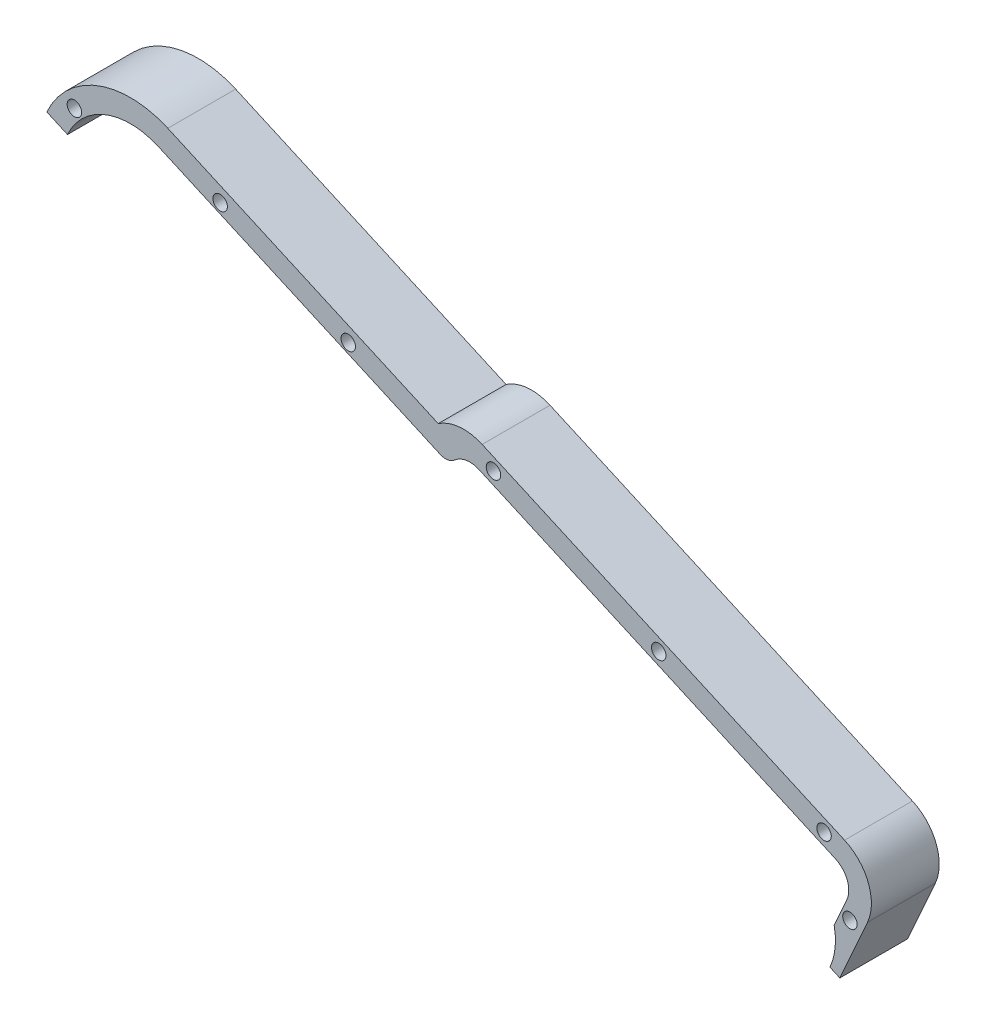
from build123d import *

# Parameters (mm, degrees)
SKETCH1_R           = 14.25
SKETCH1_R_2         = 1.7
SKETCH1_R_3         = 1.6
BOSS_EXTRUDE1_DEPTH = 15
SKETCH5_R           = 1.25
SKETCH5_R_2         = 1.6
CUT_EXTRUDE4_DEPTH  = 16
CUT_EXTRUDE5_DEPTH  = 16
FILLET1_R           = 5
FILLET2_R           = 5
CUT_EXTRUDE6_DEPTH  = 16
CUT_EXTRUDE7_DEPTH  = 16
FILLET5_R           = 3
SKETCH9_R           = 14
CUT_EXTRUDE8_DEPTH  = 16


with BuildPart() as part:
    # Sketch1 → Boss-Extrude1 (new body)
    with BuildSketch(Plane.XY):
        with BuildLine():
            Line((-72.715301765, 90.837326721), (-152.817002247, 126.544575004))
            ThreePointArc((-152.817002247, 126.544575004), (-157.784388135, 127.370762315), (-162.524605276, 125.671394934))
            Line((-162.524605276, 125.671394934), (-222.299360222, 152.317421212))
            ThreePointArc((-222.299360222, 152.317421212), (-249.039738928, 142.066706765), (-238.78902448, 115.326328059))
            Line((-238.78902448, 115.326328059), (-179.014269534, 88.680301782))
            ThreePointArc((-179.014269534, 88.680301782), (-177.109561802, 84.018800254), (-173.174612442, 80.876558766))
            Line((-173.174612442, 80.876558766), (-93.072911961, 45.169310483))
            ThreePointArc((-93.072911961, 45.169310483), (-85.421957972, 44.965480094), (-79.867786674, 50.231391692))
            Line((-79.867786674, 50.231391692), (-67.653220557, 77.632201435))
            ThreePointArc((-67.653220557, 77.632201435), (-67.449390168, 85.283155423), (-72.715301765, 90.837326721))
        make_face()
        with Locations((-230.544192351, 133.821874636)):
            Circle(SKETCH1_R, mode=Mode.SUBTRACT)
        with Locations((-95.571468701, 49.02024728)):
            Circle(SKETCH1_R_2, mode=Mode.SUBTRACT)
        with Locations((-132.105881692, 65.306335437)):
            Circle(SKETCH1_R_2, mode=Mode.SUBTRACT)
        with Locations((-168.640294682, 81.592423593)):
            Circle(SKETCH1_R_2, mode=Mode.SUBTRACT)
        with Locations((-150.318445506, 122.693638207)):
            Circle(SKETCH1_R_3, mode=Mode.SUBTRACT)
        with Locations((-113.784032516, 106.407550051)):
            Circle(SKETCH1_R_3, mode=Mode.SUBTRACT)
        with Locations((-77.249619525, 90.121461895)):
            Circle(SKETCH1_R_3, mode=Mode.SUBTRACT)
        with Locations((-81.295075004, 54.152214057)):
            Circle(SKETCH1_R_2, mode=Mode.SUBTRACT)
        with Locations((-71.52342211, 76.072861852)):
            Circle(SKETCH1_R_3, mode=Mode.SUBTRACT)
        with Locations((-168.932649456, 106.357056211)):
            Circle(SKETCH1_R_2, mode=Mode.SUBTRACT)
    extrude(amount=BOSS_EXTRUDE1_DEPTH)

    # Sketch5 → Cut-Extrude4 (cut, through all)
    with BuildSketch(Plane.XY.offset(15)):
        with Locations((-196.466353254, 99.744559857)):
            Circle(SKETCH5_R)
        with Locations((-224.780523322, 112.366278179)):
            Circle(SKETCH5_R)
        with Locations((-210.733772287, 143.877209383)):
            Circle(SKETCH5_R_2)
        with Locations((-182.419602219, 131.255491062)):
            Circle(SKETCH5_R_2)
        with Locations((-242.947351213, 145.810375386)):
            Circle(SKETCH5_R_2)
        with Locations((-247.751623016, 135.033002179)):
            Circle(SKETCH5_R)
    extrude(amount=-CUT_EXTRUDE4_DEPTH, mode=Mode.SUBTRACT)

    # Sketch6 → Cut-Extrude5 (cut, through all)
    with BuildSketch(Plane.XY.offset(15)):
        Polygon((-158.059591703, 123.407293834), (-70.184261161, 84.234764078), (-86.470349317, 47.700351088), (-174.345679859, 86.872880843), align=None)
    extrude(amount=-CUT_EXTRUDE5_DEPTH, mode=Mode.SUBTRACT)

    # Fillet1
    fillet1_edges = [part.edges().sort_by_distance(p)[0] for p in [
        (-174.345679859, 86.872880843, 7.5),
        (-158.059591703, 123.407293834, 7.5),
    ]]
    fillet(fillet1_edges, radius=FILLET1_R)

    # Fillet2
    fillet2_edges = [part.edges().sort_by_distance(p)[0] for p in [
        (-70.184261161, 84.234764078, 7.5),
        (-86.470349317, 47.700351088, 7.5),
    ]]
    fillet(fillet2_edges, radius=FILLET2_R)

    # Sketch7 → Cut-Extrude6 (cut, through all)
    with BuildSketch(Plane.XY.offset(15)):
        Polygon((-249.039738928, 142.066706765), (-73.760503615, 63.931796563), (-92.871338518, 21.060658435), (-268.15057383, 99.195568636), align=None)
    extrude(amount=-CUT_EXTRUDE6_DEPTH, mode=Mode.SUBTRACT)

    # Sketch8 → Cut-Extrude7 (cut, through all)
    with BuildSketch(Plane.XY.offset(15)):
        with BuildLine():
            Line((-147.743052942, 113.607873768), (-224.335121242, 147.750619588))
            ThreePointArc((-224.335121242, 147.750619588), (-244.45553121, 140.069846398), (-236.831015973, 119.928050513))
            Line((-236.831015973, 119.928050513), (-160.324966884, 85.309789022))
            Line((-160.324966884, 85.309789022), (-147.743052942, 113.607873768))
        make_face()
    extrude(amount=-CUT_EXTRUDE7_DEPTH, mode=Mode.SUBTRACT)

    # Fillet5
    fillet5_edges = [part.edges().sort_by_distance(p)[0] for p in [
        (-159.987852597, 119.066285997, 7.5),
    ]]
    fillet(fillet5_edges, radius=FILLET5_R)

    # Sketch9 → Cut-Extrude8 (cut, through all)
    with BuildSketch(Plane.XY.offset(15)):
        with Locations((-88.728751121, 70.604250791)):
            Circle(SKETCH9_R)
    extrude(amount=-CUT_EXTRUDE8_DEPTH, mode=Mode.SUBTRACT)


solid = part.part
